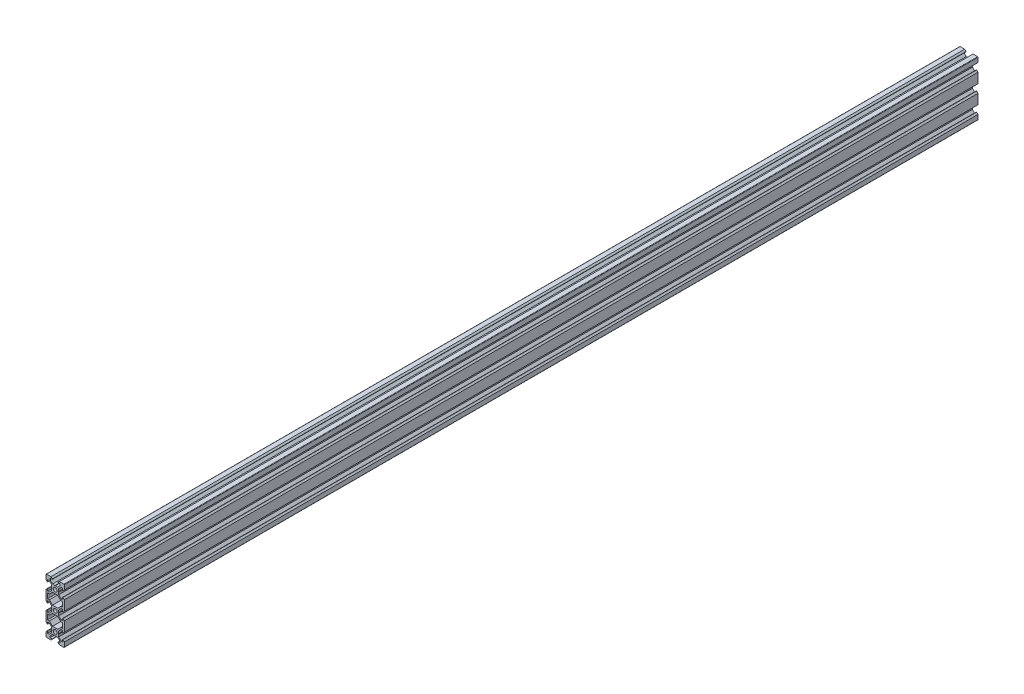
from build123d import *

# Parameters (mm, degrees)
SKETCH1_R           = 2.1
BOSS_EXTRUDE1_DEPTH = 1000


with BuildPart() as part:
    # Sketch1 → Boss-Extrude1 (new body)
    with BuildSketch(Plane.XY):
        with BuildLine():
            Line((4.58, -30), (9.5, -30))
            ThreePointArc((9.5, -30), (9.853553391, -29.853553391), (10, -29.5))
            Line((10, -29.5), (10, -24.58))
            Line((10, -24.58), (8.545, -23.125))
            Line((8.545, -23.125), (8.2, -23.125))
            Line((8.2, -23.125), (8.2, -25.5))
            Line((8.2, -25.5), (6.560660172, -25.5))
            Line((6.560660172, -25.5), (3.9, -22.839339828))
            Line((3.9, -22.839339828), (3.9, -20.21))
            Line((3.9, -20.21), (3.69, -20))
            Line((3.69, -20), (3.9, -19.79))
            Line((3.9, -19.79), (3.9, -17.160660172))
            Line((3.9, -17.160660172), (6.560660172, -14.5))
            Line((6.560660172, -14.5), (8.2, -14.5))
            Line((8.2, -14.5), (8.2, -16.875))
            Line((8.2, -16.875), (8.545, -16.875))
            Line((8.545, -16.875), (10, -15.42))
            Line((10, -15.42), (10, -4.58))
            Line((10, -4.58), (8.545, -3.125))
            Line((8.545, -3.125), (8.2, -3.125))
            Line((8.2, -3.125), (8.2, -5.5))
            Line((8.2, -5.5), (6.560660172, -5.5))
            Line((6.560660172, -5.5), (3.9, -2.839339828))
            Line((3.9, -2.839339828), (3.9, -0.21))
            Line((3.9, -0.21), (3.69, 0))
            Line((3.69, 0), (3.9, 0.21))
            Line((3.9, 0.21), (3.9, 2.839339828))
            Line((3.9, 2.839339828), (6.560660172, 5.5))
            Line((6.560660172, 5.5), (8.2, 5.5))
            Line((8.2, 5.5), (8.2, 3.125))
            Line((8.2, 3.125), (8.545, 3.125))
            Line((8.545, 3.125), (10, 4.58))
            Line((10, 4.58), (10, 15.42))
            Line((10, 15.42), (8.545, 16.875))
            Line((8.545, 16.875), (8.2, 16.875))
            Line((8.2, 16.875), (8.2, 14.5))
            Line((8.2, 14.5), (6.560660172, 14.5))
            Line((6.560660172, 14.5), (3.9, 17.160660172))
            Line((3.9, 17.160660172), (3.9, 19.79))
            Line((3.9, 19.79), (3.69, 20))
            Line((3.69, 20), (3.9, 20.21))
            Line((3.9, 20.21), (3.9, 22.839339828))
            Line((3.9, 22.839339828), (6.560660172, 25.5))
            Line((6.560660172, 25.5), (8.2, 25.5))
            Line((8.2, 25.5), (8.2, 23.125))
            Line((8.2, 23.125), (8.545, 23.125))
            Line((8.545, 23.125), (10, 24.58))
            Line((10, 24.58), (10, 29.5))
            ThreePointArc((10, 29.5), (9.853553391, 29.853553391), (9.5, 30))
            Line((9.5, 30), (4.58, 30))
            Line((4.58, 30), (3.125, 28.545))
            Line((3.125, 28.545), (3.125, 28.2))
            Line((3.125, 28.2), (5.5, 28.2))
            Line((5.5, 28.2), (5.5, 26.560660172))
            Line((5.5, 26.560660172), (2.839339828, 23.9))
            Line((2.839339828, 23.9), (0.21, 23.9))
            Line((0.21, 23.9), (0, 23.69))
            Line((0, 23.69), (-0.21, 23.9))
            Line((-0.21, 23.9), (-2.839339828, 23.9))
            Line((-2.839339828, 23.9), (-5.5, 26.560660172))
            Line((-5.5, 26.560660172), (-5.5, 28.2))
            Line((-5.5, 28.2), (-3.125, 28.2))
            Line((-3.125, 28.2), (-3.125, 28.545))
            Line((-3.125, 28.545), (-4.58, 30))
            Line((-4.58, 30), (-9.5, 30))
            ThreePointArc((-9.5, 30), (-9.853553391, 29.853553391), (-10, 29.5))
            Line((-10, 29.5), (-10, 24.58))
            Line((-10, 24.58), (-8.545, 23.125))
            Line((-8.545, 23.125), (-8.2, 23.125))
            Line((-8.2, 23.125), (-8.2, 25.5))
            Line((-8.2, 25.5), (-6.560660172, 25.5))
            Line((-6.560660172, 25.5), (-3.9, 22.839339828))
            Line((-3.9, 22.839339828), (-3.9, 20.21))
            Line((-3.9, 20.21), (-3.69, 20))
            Line((-3.69, 20), (-3.9, 19.79))
            Line((-3.9, 19.79), (-3.9, 17.160660172))
            Line((-3.9, 17.160660172), (-6.560660172, 14.5))
            Line((-6.560660172, 14.5), (-8.2, 14.5))
            Line((-8.2, 14.5), (-8.2, 16.875))
            Line((-8.2, 16.875), (-8.545, 16.875))
            Line((-8.545, 16.875), (-10, 15.42))
            Line((-10, 15.42), (-10, 4.58))
            Line((-10, 4.58), (-8.545, 3.125))
            Line((-8.545, 3.125), (-8.2, 3.125))
            Line((-8.2, 3.125), (-8.2, 5.5))
            Line((-8.2, 5.5), (-6.560660172, 5.5))
            Line((-6.560660172, 5.5), (-3.9, 2.839339828))
            Line((-3.9, 2.839339828), (-3.9, 0.21))
            Line((-3.9, 0.21), (-3.69, 0))
            Line((-3.69, 0), (-3.9, -0.21))
            Line((-3.9, -0.21), (-3.9, -2.839339828))
            Line((-3.9, -2.839339828), (-6.560660172, -5.5))
            Line((-6.560660172, -5.5), (-8.2, -5.5))
            Line((-8.2, -5.5), (-8.2, -3.125))
            Line((-8.2, -3.125), (-8.545, -3.125))
            Line((-8.545, -3.125), (-10, -4.58))
            Line((-10, -4.58), (-10, -15.42))
            Line((-10, -15.42), (-8.545, -16.875))
            Line((-8.545, -16.875), (-8.2, -16.875))
            Line((-8.2, -16.875), (-8.2, -14.5))
            Line((-8.2, -14.5), (-6.560660172, -14.5))
            Line((-6.560660172, -14.5), (-3.9, -17.160660172))
            Line((-3.9, -17.160660172), (-3.9, -19.79))
            Line((-3.9, -19.79), (-3.69, -20))
            Line((-3.69, -20), (-3.9, -20.21))
            Line((-3.9, -20.21), (-3.9, -22.839339828))
            Line((-3.9, -22.839339828), (-6.560660172, -25.5))
            Line((-6.560660172, -25.5), (-8.2, -25.5))
            Line((-8.2, -25.5), (-8.2, -23.125))
            Line((-8.2, -23.125), (-8.545, -23.125))
            Line((-8.545, -23.125), (-10, -24.58))
            Line((-10, -24.58), (-10, -29.5))
            ThreePointArc((-10, -29.5), (-9.853553391, -29.853553391), (-9.5, -30))
            Line((-9.5, -30), (-4.58, -30))
            Line((-4.58, -30), (-3.125, -28.545))
            Line((-3.125, -28.545), (-3.125, -28.2))
            Line((-3.125, -28.2), (-5.5, -28.2))
            Line((-5.5, -28.2), (-5.5, -26.560660172))
            Line((-5.5, -26.560660172), (-2.839339828, -23.9))
            Line((-2.839339828, -23.9), (-0.21, -23.9))
            Line((-0.21, -23.9), (0, -23.69))
            Line((0, -23.69), (0.21, -23.9))
            Line((0.21, -23.9), (2.839339828, -23.9))
            Line((2.839339828, -23.9), (5.5, -26.560660172))
            Line((5.5, -26.560660172), (5.5, -28.2))
            Line((5.5, -28.2), (3.125, -28.2))
            Line((3.125, -28.2), (3.125, -28.545))
            Line((3.125, -28.545), (4.58, -30))
        make_face()
        with Locations((0, -20)):
            Circle(SKETCH1_R, mode=Mode.SUBTRACT)
        Polygon((-6.239339828, -12.7), (-8.2, -12.7), (-8.2, -7.3), (-6.239339828, -7.3), (-2.839339828, -3.9), (2.839339828, -3.9), (6.239339828, -7.3), (8.2, -7.3), (8.2, -12.7), (6.239339828, -12.7), (2.839339828, -16.1), (-2.839339828, -16.1), align=None, mode=Mode.SUBTRACT)
        Polygon((-6.239339828, 7.3), (-8.2, 7.3), (-8.2, 12.7), (-6.239339828, 12.7), (-2.839339828, 16.1), (2.839339828, 16.1), (6.239339828, 12.7), (8.2, 12.7), (8.2, 7.3), (6.239339828, 7.3), (2.839339828, 3.9), (-2.839339828, 3.9), align=None, mode=Mode.SUBTRACT)
        with Locations((0, 20)):
            Circle(SKETCH1_R, mode=Mode.SUBTRACT)
        Circle(SKETCH1_R, mode=Mode.SUBTRACT)
    extrude(amount=BOSS_EXTRUDE1_DEPTH)


solid = part.part
